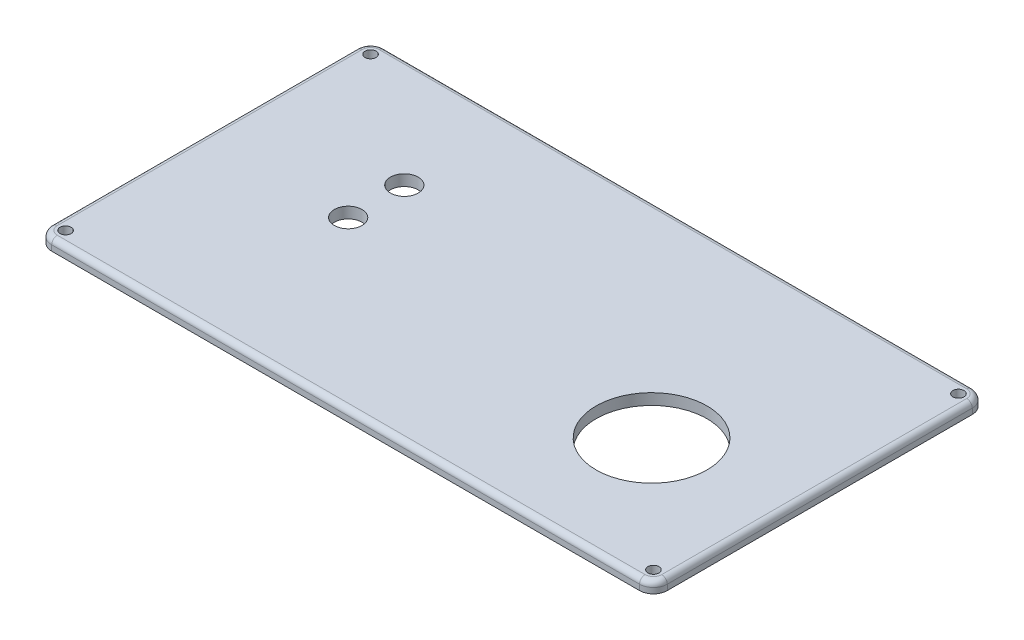
from build123d import *

# Parameters (mm, degrees)
SKETCH1_W           = 111
SKETCH1_H           = 60
BOSS_EXTRUDE1_DEPTH = 2
SKETCH2_R           = 10
SKETCH2_R_2         = 1
SKETCH2_R_3         = 2.5
CUT_EXTRUDE1_DEPTH  = 3
FILLET1_R           = 2.5
FILLET2_R           = 1


with BuildPart() as part:
    # Sketch1 → Boss-Extrude1 (new body)
    with BuildSketch(Plane(origin=(0, 0, 0), x_dir=(1, 0, 0), z_dir=(0, 1, 0))):
        with Locations((55.5, 30)):
            Rectangle(SKETCH1_W, SKETCH1_H)
    extrude(amount=BOSS_EXTRUDE1_DEPTH)

    # Sketch2 → Cut-Extrude1 (cut, through all)
    with BuildSketch(Plane(origin=(0, 2, 0), x_dir=(1, 0, 0), z_dir=(0, 1, 0))):
        with Locations((87.735933435, 22.928451884)):
            Circle(SKETCH2_R)
        with Locations((2.5, 57.5)):
            Circle(SKETCH2_R_2)
        with Locations((108.5, 57.5)):
            Circle(SKETCH2_R_2)
        with Locations((108.5, 2.5)):
            Circle(SKETCH2_R_2)
        with Locations((2.5, 2.5)):
            Circle(SKETCH2_R_2)
        with Locations((25.9625, 30)):
            Circle(SKETCH2_R_3)
        with Locations((25.9625, 40.118198487)):
            Circle(SKETCH2_R_3)
    extrude(amount=-CUT_EXTRUDE1_DEPTH, mode=Mode.SUBTRACT)

    # Fillet1
    fillet1_edges = [part.edges().sort_by_distance(p)[0] for p in [
        (0, 1, -60),
        (111, 1, -60),
        (111, 1, 0),
        (0, 1, 0),
    ]]
    fillet(fillet1_edges, radius=FILLET1_R)

    # Fillet2
    fillet2_edges = [part.edges().sort_by_distance(p)[0] for p in [
        (0, 2, -30),
        (55.5, 2, -60),
        (55.5, 2, 0),
        (111, 2, -30),
        (110.267766953, 2, -0.732233047),
        (110.267766953, 2, -59.267766953),
        (0.732233047, 2, -0.732233047),
        (0.732233047, 2, -59.267766953),
    ]]
    fillet(fillet2_edges, radius=FILLET2_R)


solid = part.part
